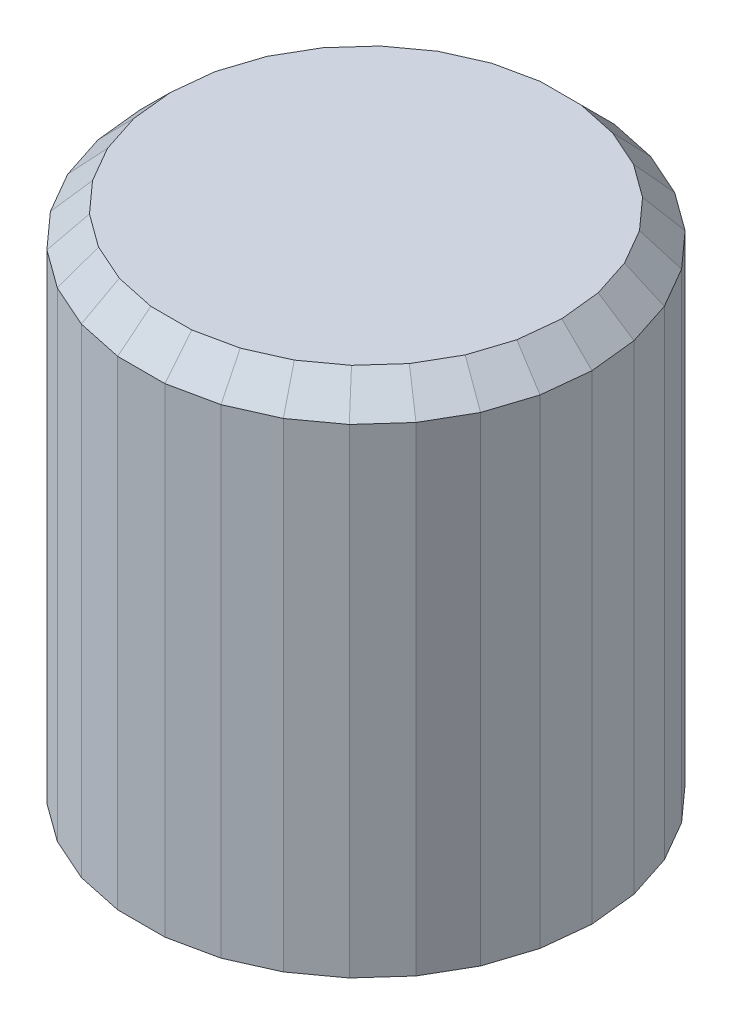
from build123d import *

# Parameters (mm, degrees)
BOSS_EXTRUDE1_DEPTH = 12
CUT_EXTRUDE2_DEPTH  = 10.5
BOSS_EXTRUDE2_DEPTH = 5
CHAMFER1_SIZE       = 1


with BuildPart() as part:
    # Sketch1 → Boss-Extrude1 (new body)
    with BuildSketch(Plane(origin=(0, 0, 0), x_dir=(1, 0, 0), z_dir=(0, 1, 0))):
        Polygon((-0.788281764, 7.5), (0.788281764, 7.5), (2.330393598, 7.172214011), (3.770656048, 6.530967854), (5.046122736, 5.604287062), (6.101049646, 4.432672033), (6.889331411, 3.067327967), (7.376516334, 1.567926949), (7.541312097, 0), (7.376516334, -1.567926949), (6.889331411, -3.067327967), (6.101049646, -4.432672033), (5.046122736, -5.604287062), (3.770656048, -6.530967854), (2.330393598, -7.172214011), (0.788281764, -7.5), (-0.788281764, -7.5), (-2.330393598, -7.172214011), (-3.770656048, -6.530967854), (-5.046122736, -5.604287062), (-6.101049646, -4.432672033), (-6.889331411, -3.067327967), (-7.376516334, -1.567926949), (-7.541312097, 0), (-7.376516334, 1.567926949), (-6.889331411, 3.067327967), (-6.101049646, 4.432672033), (-5.046122736, 5.604287062), (-3.770656048, 6.530967854), (-2.330393598, 7.172214011), align=None)
    extrude(amount=BOSS_EXTRUDE1_DEPTH)

    # Sketch3 → Cut-Extrude2 (cut)
    with BuildSketch(Plane(origin=(0, 0, 0), x_dir=(-1, 0, 0), z_dir=(0, -1, 0))):
        with BuildLine():
            Line((2.669269563, 1.625), (-2.669269563, 1.625))
            ThreePointArc((-2.669269563, 1.625), (-2.72431184, -1.530931089), (0, -3.125))
            ThreePointArc((0, -3.125), (2.72431184, -1.530931089), (2.669269563, 1.625))
        make_face()
    extrude(amount=-CUT_EXTRUDE2_DEPTH, mode=Mode.SUBTRACT)

    # Sketch4 → Boss-Extrude2 (add)
    with BuildSketch(Plane(origin=(0, 0, 0), x_dir=(-1, 0, 0), z_dir=(0, -1, 0))):
        Polygon((-0.788281764, 7.5), (-2.330393598, 7.172214011), (-3.770656048, 6.530967854), (-5.046122736, 5.604287062), (-6.101049646, 4.432672033), (-6.889331411, 3.067327967), (-7.376516334, 1.567926949), (-7.541312097, 0), (-7.376516334, -1.567926949), (-6.889331411, -3.067327967), (-6.101049646, -4.432672033), (-5.046122736, -5.604287062), (-3.770656048, -6.530967854), (-2.330393598, -7.172214011), (-0.788281764, -7.5), (0.788281764, -7.5), (2.330393598, -7.172214011), (3.770656048, -6.530967854), (5.046122736, -5.604287062), (6.101049646, -4.432672033), (6.889331411, -3.067327967), (7.376516334, -1.567926949), (7.541312097, 0), (7.376516334, 1.567926949), (6.889331411, 3.067327967), (6.101049646, 4.432672033), (5.046122736, 5.604287062), (3.770656048, 6.530967854), (2.330393598, 7.172214011), (0.788281764, 7.5), align=None)
        with BuildLine():
            ThreePointArc((-4, 0), (0, -4), (4, 0))
            ThreePointArc((4, 0), (0, 4), (-4, 0))
        make_face(mode=Mode.SUBTRACT)
    extrude(amount=BOSS_EXTRUDE2_DEPTH)

    # Chamfer1
    chamfer1_edges = [part.edges().sort_by_distance(p)[0] for p in [
        (7.458914215, 12, -0.783963475),
        (7.132923872, 12, -2.317627458),
        (6.495190528, 12, -3.75),
        (5.573586191, 12, -5.018479548),
        (4.408389392, 12, -6.067627458),
        (3.050524823, 12, -6.851590932),
        (-1.559337681, 12, -7.336107006),
        (-3.050524823, 12, -6.851590932),
        (-4.408389392, 12, -6.067627458),
        (-5.573586191, 12, -5.018479548),
        (-6.495190528, 12, -3.75),
        (-7.132923872, 12, -2.317627458),
        (-7.458914215, 12, -0.783963475),
        (-7.458914215, 12, 0.783963475),
        (-7.132923872, 12, 2.317627458),
        (-6.495190528, 12, 3.75),
        (1.559337681, 12, -7.336107006),
        (-5.573586191, 12, 5.018479548),
        (-4.408389392, 12, 6.067627458),
        (-3.050524823, 12, 6.851590932),
        (-1.559337681, 12, 7.336107006),
        (0, 12, 7.5),
        (1.559337681, 12, 7.336107006),
        (3.050524823, 12, 6.851590932),
        (4.408389392, 12, 6.067627458),
        (5.573586191, 12, 5.018479548),
        (6.495190528, 12, 3.75),
        (0, 12, -7.5),
        (7.132923872, 12, 2.317627458),
        (7.458914215, 12, 0.783963475),
    ]]
    chamfer(chamfer1_edges, length=CHAMFER1_SIZE)


solid = part.part
